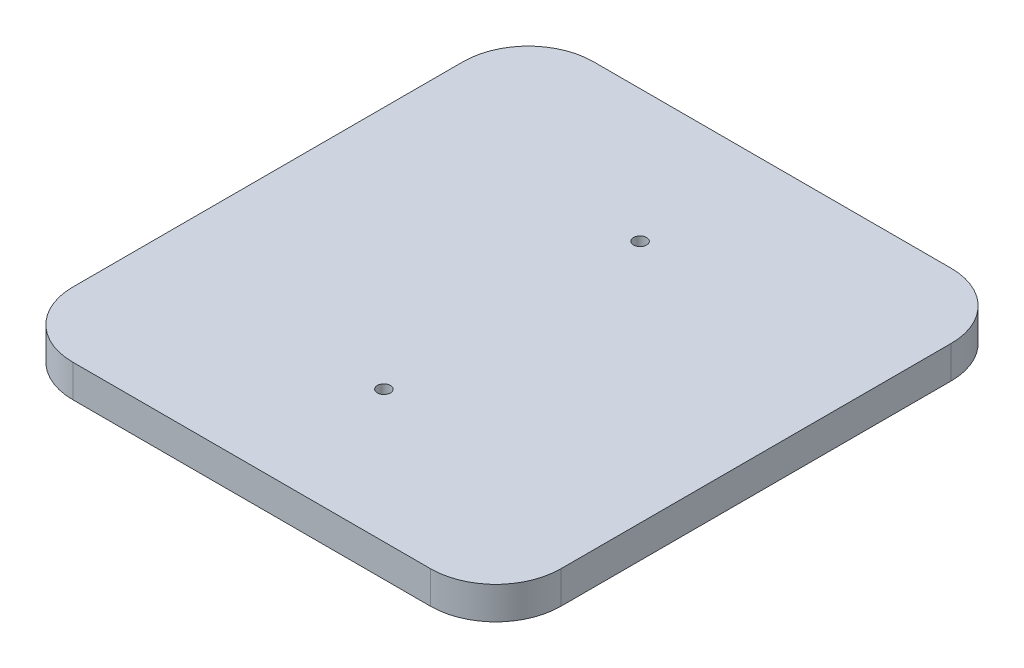
from build123d import *

# Parameters (mm, degrees)
BOSS_EXTRUDE1_DEPTH         = 12.7
F_1_4_20_TAPPED_HOLE2_D     = 5.1054
F_1_4_20_TAPPED_HOLE2_DEPTH = 19.05
F_1_4_20_TAPPED_HOLE2_TIP   = 1.533816902


with BuildPart() as part:
    # Sketch1 → Boss-Extrude1 (new body)
    with BuildSketch(Plane(origin=(0, 0, 0), x_dir=(1, 0, 0), z_dir=(0, 1, 0))):
        with BuildLine():
            Line((25.4, 0), (165.1, 0))
            ThreePointArc((165.1, 0), (183.060512242, 7.439487758), (190.5, 25.4))
            Line((190.5, 25.4), (190.5, 177.8))
            ThreePointArc((190.5, 177.8), (183.060512242, 195.760512242), (165.1, 203.2))
            Line((165.1, 203.2), (25.4, 203.2))
            ThreePointArc((25.4, 203.2), (7.439487758, 195.760512242), (0, 177.8))
            Line((0, 177.8), (0, 25.4))
            ThreePointArc((0, 25.4), (7.439487758, 7.439487758), (25.4, 0))
        make_face()
    extrude(amount=BOSS_EXTRUDE1_DEPTH)

    # 1/4-20 Tapped Hole2
    with Locations(Plane(origin=(0, 12.7, 0), x_dir=(1, 0, 0), z_dir=(0, 1, 0))):
        with Locations((95.25, 151.6), (95.25, 51.6)):
            Hole(F_1_4_20_TAPPED_HOLE2_D / 2, depth=F_1_4_20_TAPPED_HOLE2_DEPTH)
            with Locations((0, 0, -(F_1_4_20_TAPPED_HOLE2_DEPTH + F_1_4_20_TAPPED_HOLE2_TIP / 2))):  # 118° drill point
                Cone(0, F_1_4_20_TAPPED_HOLE2_D / 2, F_1_4_20_TAPPED_HOLE2_TIP, mode=Mode.SUBTRACT)


solid = part.part
